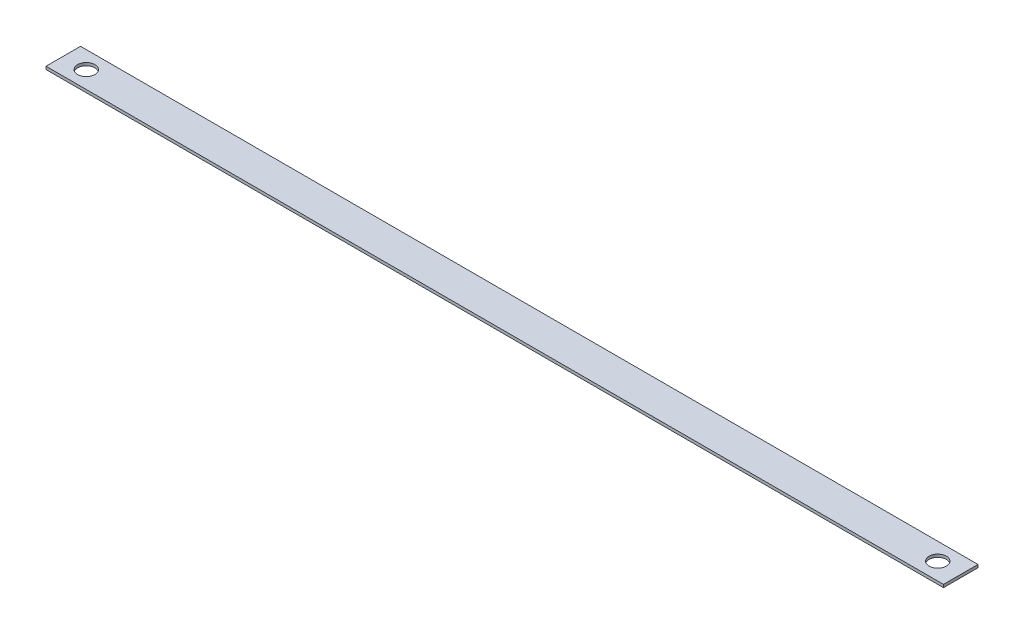
from build123d import *

# Parameters (mm, degrees)
SKETCH1_W           = 990.6
SKETCH1_H           = 38.1
SKETCH1_R           = 9.525
BOSS_EXTRUDE1_DEPTH = 3.175


with BuildPart() as part:
    # Sketch1 → Boss-Extrude1 (new body)
    with BuildSketch(Plane(origin=(0, 0, 0), x_dir=(1, 0, 0), z_dir=(0, 1, 0))):
        Rectangle(SKETCH1_W, SKETCH1_H)
        with Locations((-469.9, 0)):
            Circle(SKETCH1_R, mode=Mode.SUBTRACT)
        with Locations((469.9, 0)):
            Circle(SKETCH1_R, mode=Mode.SUBTRACT)
    extrude(amount=BOSS_EXTRUDE1_DEPTH)


solid = part.part
